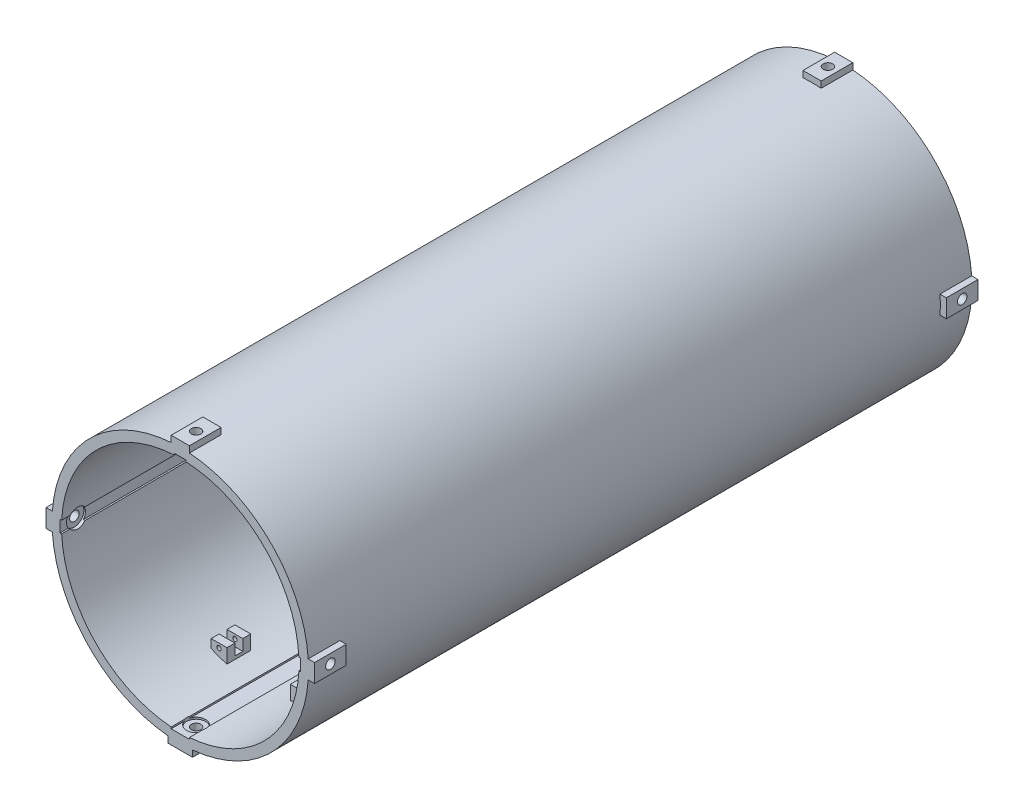
from build123d import *

# Parameters (mm, degrees)
EXTRUDE_1_DEPTH                  = 419
CUT_EXTRUDE_START                = -20
SKETCH_2_R                       = 101
SKETCH_2_R_2                     = 81
CUT_EXTRUDE_1_DEPTH              = 379
SKETCH_3_R                       = 75
CUT_EXTRUDE_2_DEPTH              = 436.82575288
SKETCH_4_W                       = 11.5
SKETCH_4_H                       = 1
SKETCH_4_W_2                     = 1
SKETCH_4_H_2                     = 7.5
SKETCH_4_W_3                     = 7.5
CUT_EXTRUDE_3_DEPTH              = 436.82575288
SKETCH_5_R                       = 3
CUT_EXTRUDE_4_DEPTH              = 457.705569743
CUT_EXTRUDE_START_2              = -1
SKETCH_7_R                       = 6
CUT_EXTRUDE_5_DEPTH              = 2.146576
PATTERN_CIRCULAR_1_COUNT         = 4
EXTRUDE_START                    = -49.5
SKETCH_8_W                       = 10
SKETCH_8_H                       = 9
EXTRUDE_2_DEPTH                  = 15
SKETCH_9_W                       = 10
SKETCH_9_H                       = 5
CUT_EXTRUDE_6_DEPTH              = 7
SKETCH_10_R                      = 1.35
CUT_EXTRUDE_7_DEPTH              = 389.475658114
PATTERN_LINEAR_1_COUNT           = 2
PATTERN_LINEAR_1_PITCH           = 305
PATTERN_START                    = -49.5
PATTERN_LINEAR_1_COPY_1_SKETCH_W = 10
PATTERN_LINEAR_1_COPY_1_SKETCH_H = 9
PATTERN_LINEAR_1_COPY_1_DEPTH    = 15
PATTERN_LINEAR_1_COPY_2_SKETCH_W = 10
PATTERN_LINEAR_1_COPY_2_SKETCH_H = 5
PATTERN_LINEAR_1_COPY_2_DEPTH    = 7
PATTERN_LINEAR_1_COPY_3_SKETCH_R = 1.35
PATTERN_LINEAR_1_COPY_3_DEPTH    = 389.475658114


with BuildPart() as part:
    # Sketch 1 → Extrude 1 (new body)
    with BuildSketch(Plane.XY):
        with BuildLine():
            Line((-7.75, -80.628391402), (-7.75, -84.641721049))
            Line((-7.75, -84.641721049), (7.75, -84.641721049))
            Line((7.75, -84.641721049), (7.75, -80.628391402))
            ThreePointArc((7.75, -80.628391402), (57.980828979, -56.561678467), (80.79565273, -5.75))
            Line((80.79565273, -5.75), (84.802968325, -5.75))
            Line((84.802968325, -5.75), (84.802968325, 5.75))
            Line((84.802968325, 5.75), (80.79565273, 5.75))
            ThreePointArc((80.79565273, 5.75), (57.275649276, 57.275649276), (5.75, 80.79565273))
            Line((5.75, 80.79565273), (5.75, 84.802968325))
            Line((5.75, 84.802968325), (-5.75, 84.802968325))
            Line((-5.75, 84.802968325), (-5.75, 80.79565273))
            ThreePointArc((-5.75, 80.79565273), (-57.275649276, 57.275649276), (-80.79565273, 5.75))
            Line((-80.79565273, 5.75), (-84.802968325, 5.75))
            Line((-84.802968325, 5.75), (-84.802968325, -5.75))
            Line((-84.802968325, -5.75), (-80.79565273, -5.75))
            ThreePointArc((-80.79565273, -5.75), (-57.980828979, -56.561678467), (-7.75, -80.628391402))
        make_face()
    extrude(amount=EXTRUDE_1_DEPTH)

    # Sketch 2 → Cut-Extrude 1 (cut)
    with BuildSketch(Plane.XY.offset(419).offset(CUT_EXTRUDE_START)):
        Circle(SKETCH_2_R)
        with Locations(Location((0, 0, 0), (0, 0, 175.929283224))):
            Circle(SKETCH_2_R_2, mode=Mode.SUBTRACT)
    extrude(amount=-CUT_EXTRUDE_1_DEPTH, mode=Mode.SUBTRACT)

    # Sketch 3 → Cut-Extrude 2 (cut, through all)
    with BuildSketch(Plane.XY.offset(419)):
        Circle(SKETCH_3_R)
    extrude(amount=-CUT_EXTRUDE_2_DEPTH, mode=Mode.SUBTRACT)

    # Sketch 4 → Cut-Extrude 3 (cut, through all)
    with BuildSketch(Plane.XY.offset(419)):
        with Locations((0, -75.279258488)):
            Rectangle(SKETCH_4_W, SKETCH_4_H)
        with Locations((-75.406191333, 0)):
            Rectangle(SKETCH_4_W_2, SKETCH_4_H_2)
        with Locations((0, 75.406191333)):
            Rectangle(SKETCH_4_W_3, SKETCH_4_H)
        with Locations((75.406191333, 0)):
            Rectangle(SKETCH_4_W_2, SKETCH_4_H_2)
    extrude(amount=-CUT_EXTRUDE_3_DEPTH, mode=Mode.SUBTRACT)

    # Sketch 5 → Cut-Extrude 4 (cut, through all)
    with BuildSketch(Plane(origin=(-75.906191333, 0, 0), x_dir=(0, 0, -1), z_dir=(1, 0, 0))):
        with Locations((-409, 0)):
            Circle(SKETCH_5_R)
        with Locations((-10, 0)):
            Circle(SKETCH_5_R)
    cut_extrude_4 = extrude(amount=-CUT_EXTRUDE_4_DEPTH, mode=Mode.SUBTRACT)

    # Sketch 7 → Cut-Extrude 5 (cut)
    with BuildSketch(Plane(origin=(-75.906191333, 0, 0), x_dir=(0, 0, -1), z_dir=(1, 0, 0)).offset(CUT_EXTRUDE_START_2)):
        with Locations((-409, 0)):
            Circle(SKETCH_7_R)
        with Locations((-10, 0)):
            Circle(SKETCH_7_R)
    cut_extrude_5 = extrude(amount=CUT_EXTRUDE_5_DEPTH, mode=Mode.SUBTRACT)

    # Pattern Circular 1: Cut-Extrude 4, Cut-Extrude 5 ×4 about axis
    pattern_circular_1_axis = Axis((0, 0, 0), (0, 0, 1))
    add([cut_extrude_4.rotate(pattern_circular_1_axis, i * 360 / PATTERN_CIRCULAR_1_COUNT) for i in range(1, PATTERN_CIRCULAR_1_COUNT)], mode=Mode.SUBTRACT)
    add([cut_extrude_5.rotate(pattern_circular_1_axis, i * 360 / PATTERN_CIRCULAR_1_COUNT) for i in range(1, PATTERN_CIRCULAR_1_COUNT)], mode=Mode.SUBTRACT)

    # Sketch 8 → Extrude 2 (add)
    with BuildSketch(Plane.XY.offset(419).offset(EXTRUDE_START)):
        with Locations((-25, -67.784161474)):
            Rectangle(SKETCH_8_W, SKETCH_8_H)
    extrude_2 = extrude(amount=-EXTRUDE_2_DEPTH)

    # Sketch 9 → Cut-Extrude 6 (cut)
    with BuildSketch(Plane(origin=(0, -63.284161474, 0), x_dir=(1, 0, 0), z_dir=(0, 1, 0))):
        with Locations((-25, -362)):
            Rectangle(SKETCH_9_W, SKETCH_9_H)
    cut_extrude_6 = extrude(amount=-CUT_EXTRUDE_6_DEPTH, mode=Mode.SUBTRACT)

    # Sketch 10 → Cut-Extrude 7 (cut, through all)
    with BuildSketch(Plane.XY.offset(369.5)):
        with Locations((-25, -66)):
            Circle(SKETCH_10_R)
    cut_extrude_7 = extrude(amount=-CUT_EXTRUDE_7_DEPTH, mode=Mode.SUBTRACT)

    # Mirror 1: Extrude 2, Cut-Extrude 6, Cut-Extrude 7 across plane
    add(extrude_2.mirror(Plane(origin=(0, 0, 0), x_dir=(0, 0, 1), z_dir=(1, 0, 0))))
    add(cut_extrude_6.mirror(Plane(origin=(0, 0, 0), x_dir=(0, 0, 1), z_dir=(1, 0, 0))), mode=Mode.SUBTRACT)
    add(cut_extrude_7.mirror(Plane(origin=(0, 0, 0), x_dir=(0, 0, 1), z_dir=(1, 0, 0))), mode=Mode.SUBTRACT)

    # Pattern Linear 1: Extrude 2, Cut-Extrude 6, Cut-Extrude 7 ×2
    with Locations(*[(0, 0, -i * PATTERN_LINEAR_1_PITCH) for i in range(1, PATTERN_LINEAR_1_COUNT)]):
        add(extrude_2)
        add(cut_extrude_6, mode=Mode.SUBTRACT)
        add(cut_extrude_7, mode=Mode.SUBTRACT)

    # Pattern Linear 1 copy 1 sketch → Pattern Linear 1 copy 1 (add)
    with BuildSketch(Plane(origin=(0, 0, 114), x_dir=(-1, 0, 0), z_dir=(0, 0, 1)).offset(PATTERN_START)):
        with Locations((-25, 67.784161474)):
            Rectangle(PATTERN_LINEAR_1_COPY_1_SKETCH_W, PATTERN_LINEAR_1_COPY_1_SKETCH_H)
    extrude(amount=-PATTERN_LINEAR_1_COPY_1_DEPTH)

    # Pattern Linear 1 copy 2 sketch → Pattern Linear 1 copy 2 (cut)
    with BuildSketch(Plane(origin=(0, -63.284161474, -305), x_dir=(-1, 0, 0), z_dir=(0, 1, 0))):
        with Locations((-25, 362)):
            Rectangle(PATTERN_LINEAR_1_COPY_2_SKETCH_W, PATTERN_LINEAR_1_COPY_2_SKETCH_H)
    extrude(amount=-PATTERN_LINEAR_1_COPY_2_DEPTH, mode=Mode.SUBTRACT)

    # Pattern Linear 1 copy 3 sketch → Pattern Linear 1 copy 3 (cut, through all)
    with BuildSketch(Plane(origin=(0, 0, 64.5), x_dir=(-1, 0, 0), z_dir=(0, 0, 1))):
        with Locations((-25, 66)):
            Circle(PATTERN_LINEAR_1_COPY_3_SKETCH_R)
    extrude(amount=-PATTERN_LINEAR_1_COPY_3_DEPTH, mode=Mode.SUBTRACT)


solid = part.part
